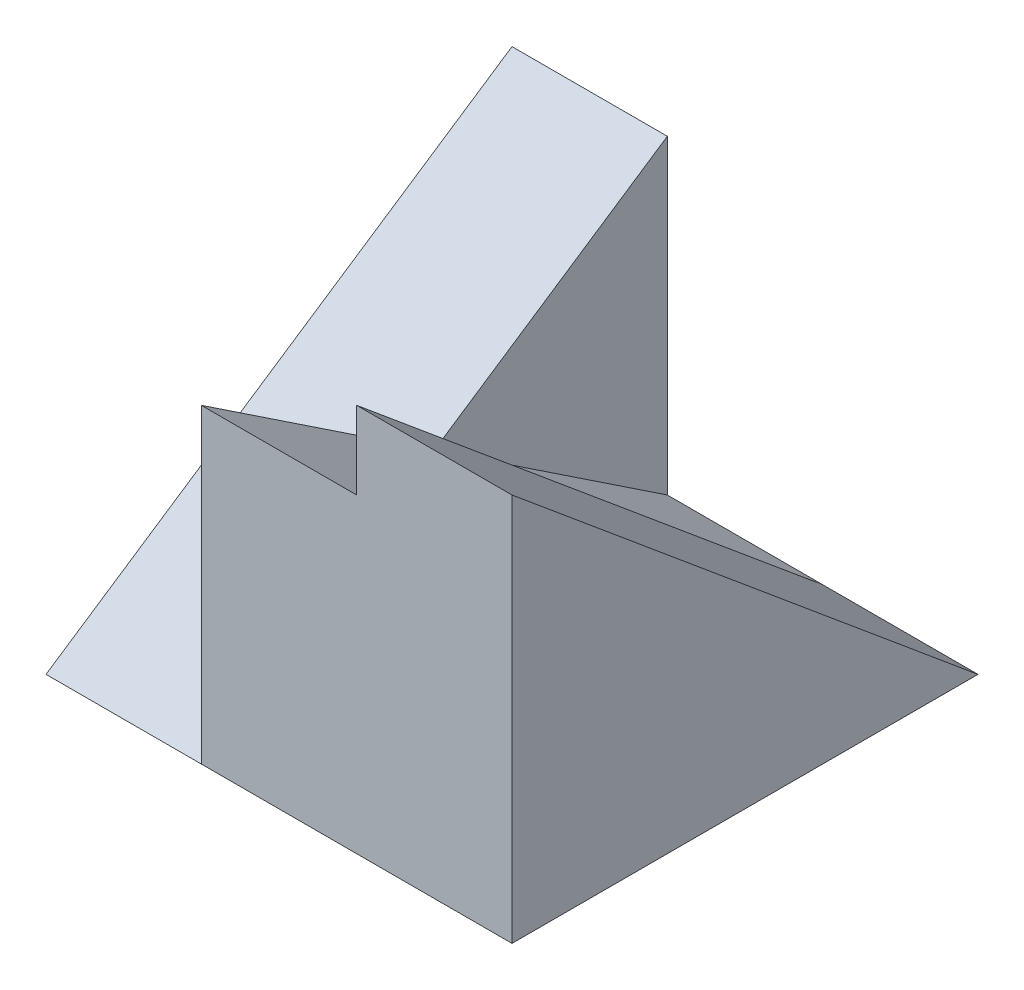
from build123d import *

# Parameters (mm, degrees)
SKETCH1_W           = 6
SKETCH1_H           = 6
BOSS_EXTRUDE1_DEPTH = 5
CUT_EXTRUDE1_DEPTH  = 2
CUT_EXTRUDE2_DEPTH  = 2
CUT_EXTRUDE3_DEPTH  = 2


with BuildPart() as part:
    # Sketch1 → Boss-Extrude1 (new body)
    with BuildSketch(Plane(origin=(0, 0, 0), x_dir=(1, 0, 0), z_dir=(0, 1, 0))):
        Rectangle(SKETCH1_W, SKETCH1_H)
    extrude(amount=BOSS_EXTRUDE1_DEPTH)

    # Sketch2 → Cut-Extrude1 (cut)
    with BuildSketch(Plane.ZY.offset(3)):
        Polygon((3, 5), (-3, 5), (-3, 4), (3, 0), align=None)
    extrude(amount=-CUT_EXTRUDE1_DEPTH, mode=Mode.SUBTRACT)

    # Sketch3 → Cut-Extrude2 (cut)
    with BuildSketch(Plane.ZY.offset(1)):
        Polygon((-3, 0), (3, 4), (3, 5), (-3, 5), align=None)
    extrude(amount=-CUT_EXTRUDE2_DEPTH, mode=Mode.SUBTRACT)

    # Sketch4 → Cut-Extrude3 (cut)
    with BuildSketch(Plane.ZY.offset(-1)):
        Polygon((-3, 0), (3, 5), (-3, 5), align=None)
    extrude(amount=-CUT_EXTRUDE3_DEPTH, mode=Mode.SUBTRACT)


solid = part.part
